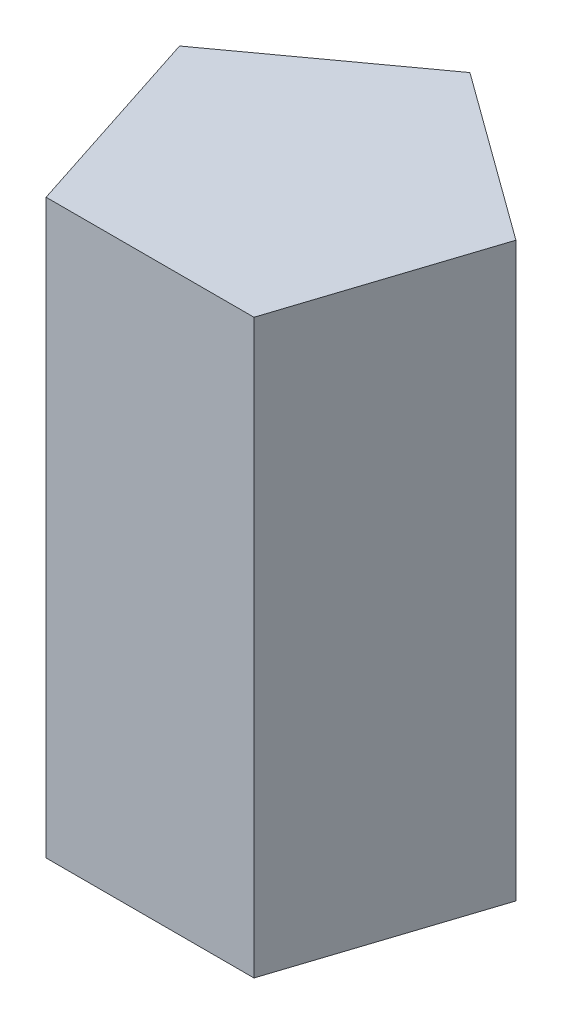
from build123d import *

# Parameters (mm, degrees)
EXTRUDE1_DEPTH = 20


with BuildPart() as part:
    # Sketch1 → Extrude1 (new body)
    with BuildSketch(Plane(origin=(0, 0, 0), x_dir=(1, 0, 0), z_dir=(0, 1, 0))):
        Polygon((5.877852523, 1.909830056), (0, 6.180339887), (-5.877852523, 1.909830056), (-3.63271264, -5), (3.63271264, -5), align=None)
    extrude(amount=EXTRUDE1_DEPTH)


solid = part.part
